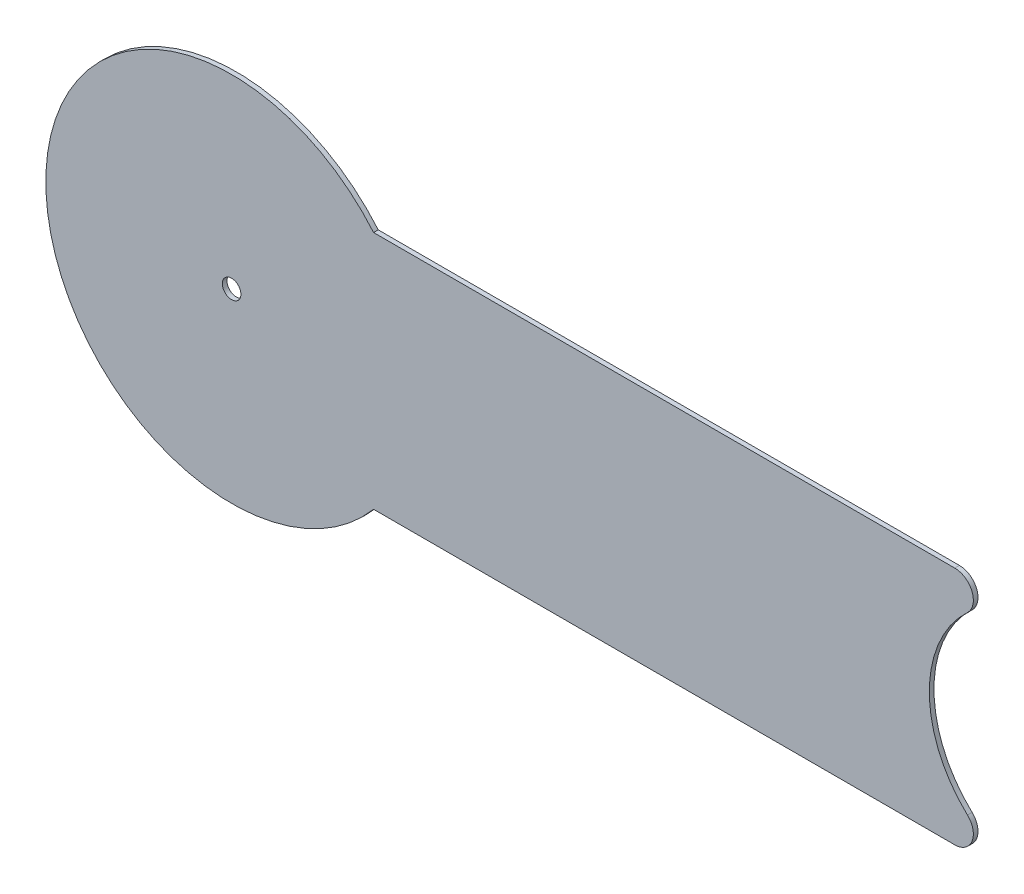
from build123d import *

# Parameters (mm, degrees)
SKETCH1_R           = 3.175
BOSS_EXTRUDE1_DEPTH = 1.5875


with BuildPart() as part:
    # Sketch1 → Boss-Extrude1 (new body)
    with BuildSketch(Plane.XY):
        with BuildLine():
            Line((247.146000248, -40.9575), (48.525593183, -40.9575))
            ThreePointArc((48.525593183, -40.9575), (-63.5, 0), (48.525593183, 40.9575))
            Line((48.525593183, 40.9575), (247.146000248, 40.9575))
            ThreePointArc((247.146000248, 40.9575), (253.054475846, 36.933959995), (251.475396188, 29.962197987))
            ThreePointArc((251.475396188, 29.962197987), (238.4425, 0), (251.475396188, -29.962197987))
            ThreePointArc((251.475396188, -29.962197987), (253.054475846, -36.933959995), (247.146000248, -40.9575))
        make_face()
        Circle(SKETCH1_R, mode=Mode.SUBTRACT)
    extrude(amount=BOSS_EXTRUDE1_DEPTH)


solid = part.part
